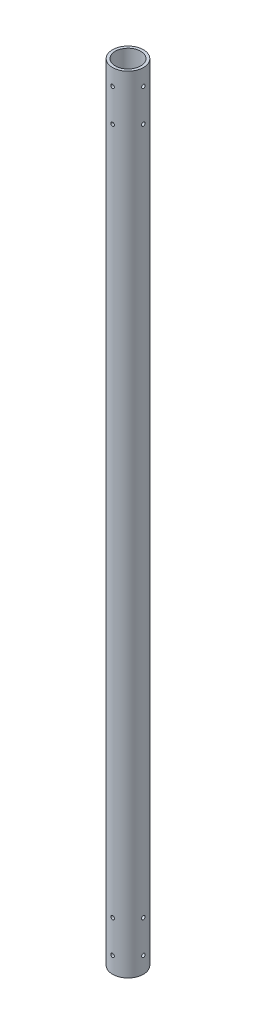
from build123d import *

# Parameters (mm, degrees)
SKETCH1_R           = 5.9944
SKETCH1_R_2         = 4.953
BOSS_EXTRUDE1_DEPTH = 304.8
CUT_EXTRUDE1_START  = -1.090901
SKETCH2_R           = 0.6985
CUT_EXTRUDE1_DEPTH  = 1.090901
CIRPATTERN1_COUNT   = 4


with BuildPart() as part:
    # Sketch1 → Boss-Extrude1 (new body)
    with BuildSketch(Plane(origin=(0, 0, 0), x_dir=(1, 0, 0), z_dir=(0, 1, 0))):
        Circle(SKETCH1_R)
        Circle(SKETCH1_R_2, mode=Mode.SUBTRACT)
    extrude(amount=BOSS_EXTRUDE1_DEPTH)

    # Sketch2 → Cut-Extrude1 (cut)
    with BuildSketch(Plane.XY.offset(5.9944).offset(CUT_EXTRUDE1_START)):
        with Locations((0, 6.35)):
            Circle(SKETCH2_R)
        with Locations((0, 19.05)):
            Circle(SKETCH2_R)
        with Locations((0, 298.45)):
            Circle(SKETCH2_R)
        with Locations((0, 285.75)):
            Circle(SKETCH2_R)
    cut_extrude1 = extrude(amount=CUT_EXTRUDE1_DEPTH, mode=Mode.SUBTRACT)

    # CirPattern1: Cut-Extrude1 ×4 about axis
    cirpattern1_axis = Axis((0, 304.8, 0), (0, 1, 0))
    for i in range(1, CIRPATTERN1_COUNT):
        add(cut_extrude1.rotate(cirpattern1_axis, i * 360 / CIRPATTERN1_COUNT), mode=Mode.SUBTRACT)


solid = part.part
